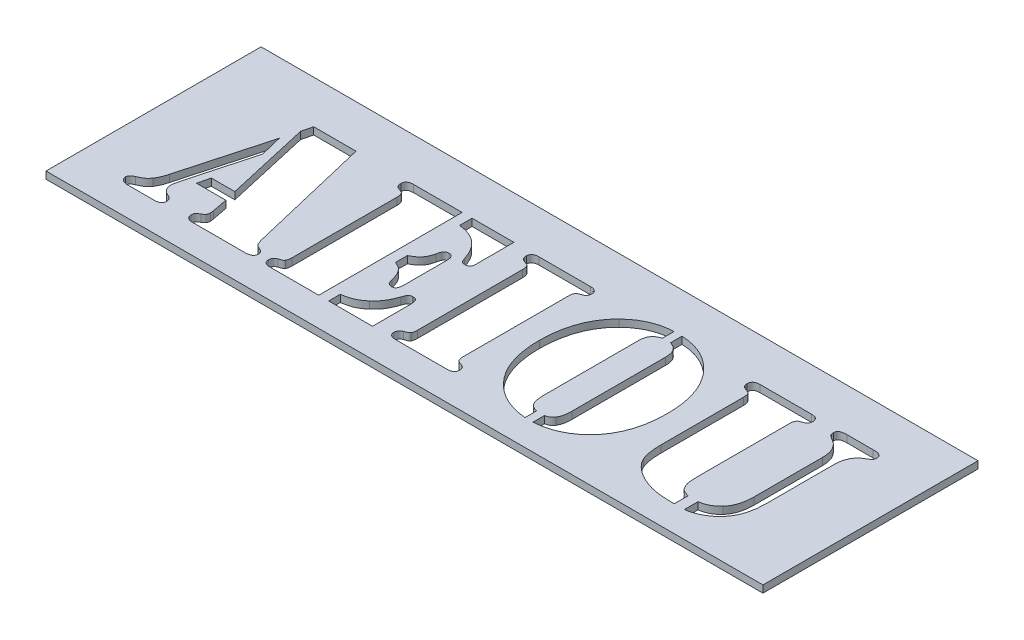
from build123d import *

# Parameters (mm, degrees)
SKETCH1_W           = 50
SKETCH1_H           = 15
BOSS_EXTRUDE1_DEPTH = 0.5
CUT_EXTRUDE1_REACH  = 2.5


with BuildPart() as part:
    # Sketch1 → Boss-Extrude1 (new body)
    with BuildSketch(Plane(origin=(0, 0, 0), x_dir=(1, 0, 0), z_dir=(0, 1, 0))):
        Rectangle(SKETCH1_W, SKETCH1_H)
    extrude(amount=BOSS_EXTRUDE1_DEPTH)

    # Sketch2 → Cut-Extrude1 (cut, up to next)
    with BuildSketch(Plane(origin=(0, 0.5, 0), x_dir=(1, 0, 0), z_dir=(0, 1, 0)), mode=Mode.PRIVATE) as cut_extrude1_sk1:
        with BuildLine():
            Line((-18.337673611, 4.507033689), (-15.386284722, 4.507033689))
            Line((-15.386284722, 4.507033689), (-13.335503472, -4.101907283))
            add(Edge.make_bspline(
                [(-13.335503472, -4.101907283), (-13.31571659, -4.173193323), (-13.277982556, -4.309137424), (-13.227253077, -4.440773778), (-13.203125, -4.503382978)],
                knots=[0, 0, 0, 0, 0.00022179, 0.000422958, 0.000422958, 0.000422958, 0.000422958], degree=3))
            add(Edge.make_bspline(
                [(-13.203125, -4.503382978), (-13.189801958, -4.526708407), (-13.162169427, -4.575086298), (-13.09409429, -4.634093988), (-13.009454398, -4.688410957), (-12.943250713, -4.716359995), (-12.907986111, -4.731247561)],
                knots=[0, 0, 0, 0, 8.006e-05, 0.000166048, 0.00026658, 0.000381166, 0.000381166, 0.000381166, 0.000381166], degree=3))
            add(Edge.make_bspline(
                [(-12.907986111, -4.731247561), (-12.852666047, -4.75584302), (-12.757778354, -4.79803036), (-12.641851728, -4.881220271), (-12.575758787, -4.989270356), (-12.571630909, -5.068863034), (-12.569444444, -5.111021867)],
                knots=[0, 0, 0, 0, 0.000181489, 0.000311299, 0.00042221, 0.00054712, 0.00054712, 0.00054712, 0.00054712], degree=3))
            add(Edge.make_bspline(
                [(-12.569444444, -5.111021867), (-12.570763223, -5.140939839), (-12.573307323, -5.198655589), (-12.602706683, -5.278735913), (-12.650267163, -5.347111766), (-12.717303399, -5.401839339), (-12.802967775, -5.442991364), (-12.905532483, -5.472848329), (-13.026827736, -5.489279696), (-13.113376601, -5.491680641), (-13.159722222, -5.492966311)],
                knots=[0, 0, 0, 0, 8.9398e-05, 0.000172461, 0.000251931, 0.000336677, 0.000428876, 0.000535302, 0.000655915, 0.000794957, 0.000794957, 0.000794957, 0.000794957], degree=3))
            Line((-13.159722222, -5.492966311), (-16.814236111, -5.492966311))
            add(Edge.make_bspline(
                [(-16.814236111, -5.492966311), (-16.848382867, -5.492037961), (-16.914538807, -5.490239376), (-17.00724797, -5.467551949), (-17.09105245, -5.435117567), (-17.162233739, -5.387795061), (-17.219559933, -5.328245792), (-17.262338966, -5.259855291), (-17.286573738, -5.181299037), (-17.289931903, -5.126374168), (-17.291666667, -5.098001033)],
                knots=[0, 0, 0, 0, 0.000102204, 0.00019801, 0.000284653, 0.000370723, 0.000452067, 0.000530972, 0.000610589, 0.000695669, 0.000695669, 0.000695669, 0.000695669], degree=3))
            add(Edge.make_bspline(
                [(-17.291666667, -5.098001033), (-17.290296603, -5.054174847), (-17.287858408, -4.976180792), (-17.249915704, -4.884635257), (-17.198259915, -4.82860937), (-17.141642569, -4.786075371), (-17.071172085, -4.735594692), (-17.01571023, -4.704618629), (-16.985677083, -4.687844783)],
                knots=[0, 0, 0, 0, 0.000130858, 0.000232877, 0.000288205, 0.000357684, 0.000444976, 0.000548075, 0.000548075, 0.000548075, 0.000548075], degree=3))
            add(Edge.make_bspline(
                [(-16.985677083, -4.687844783), (-16.9451778, -4.662997846), (-16.87225783, -4.618260316), (-16.78822521, -4.527889373), (-16.740696936, -4.419393316), (-16.737706092, -4.341127905), (-16.736111111, -4.299389922)],
                knots=[0, 0, 0, 0, 0.000142057, 0.000255777, 0.000364631, 0.000489012, 0.000489012, 0.000489012, 0.000489012], degree=3))
            add(Edge.make_bspline(
                [(-16.736111111, -4.299389922), (-16.736415512, -4.259500284), (-16.736988204, -4.184452867), (-16.749691292, -4.110507236), (-16.755642361, -4.075865617)],
                knots=[0, 0, 0, 0, 0.000119437, 0.000224705, 0.000224705, 0.000224705, 0.000224705], degree=3))
            Line((-16.755642361, -4.075865617), (-16.968315972, -2.992966311))
            Line((-16.968315972, -2.992966311), (-19.010416667, -2.992966311))
            Line((-19.010416667, -2.992966311), (-18.812934028, -2.159632978))
            Line((-18.812934028, -2.159632978), (-17.172309028, -2.159632978))
            Line((-17.172309028, -2.159632978), (-18.519965278, 3.777867022))
            Line((-18.519965278, 3.777867022), (-18.337673611, 4.507033689))
        make_face()
    cut_extrude1_tool1 = extrude(cut_extrude1_sk1.sketch, amount=-CUT_EXTRUDE1_REACH, mode=Mode.PRIVATE) & part.part
    add(cut_extrude1_tool1.solids().sort_by_distance((-15.934964, 0.5, 0.750702))[0], mode=Mode.SUBTRACT)
    # Sketch2 → Cut-Extrude1 (cut, up to next)
    with BuildSketch(Plane(origin=(0, 0.5, 0), x_dir=(1, 0, 0), z_dir=(0, 1, 0)), mode=Mode.PRIVATE) as cut_extrude1_sk2:
        with BuildLine():
            Line((-18.843315972, 2.619012856), (-18.470052083, 1.095575356))
            Line((-18.470052083, 1.095575356), (-19.735243056, -3.613626033))
            add(Edge.make_bspline(
                [(-19.735243056, -3.613626033), (-19.75113154, -3.678415772), (-19.781579767, -3.802576928), (-19.78840363, -3.930202275), (-19.791666667, -3.9912302)],
                knots=[0, 0, 0, 0, 0.000199617, 0.000382541, 0.000382541, 0.000382541, 0.000382541], degree=3))
            add(Edge.make_bspline(
                [(-19.791666667, -3.9912302), (-19.787963166, -4.062970612), (-19.780891211, -4.19996126), (-19.702393275, -4.386972131), (-19.578817938, -4.544382617), (-19.46462721, -4.611690815), (-19.405381944, -4.646612144)],
                knots=[0, 0, 0, 0, 0.000214009, 0.000408657, 0.000598455, 0.000803105, 0.000803105, 0.000803105, 0.000803105], degree=3))
            Line((-19.405381944, -4.646612144), (-19.175347222, -4.763799644))
            add(Edge.make_bspline(
                [(-19.175347222, -4.763799644), (-19.142106966, -4.783717378), (-19.078737399, -4.82168875), (-19.00680033, -4.907779295), (-18.964568383, -5.012653825), (-18.960459118, -5.088926146), (-18.958333333, -5.128382978)],
                knots=[0, 0, 0, 0, 0.000115569, 0.000220322, 0.000330337, 0.000448246, 0.000448246, 0.000448246, 0.000448246], degree=3))
            add(Edge.make_bspline(
                [(-18.958333333, -5.128382978), (-18.959020346, -5.156816813), (-18.960335004, -5.211227419), (-18.985850009, -5.286539465), (-19.023169141, -5.351042161), (-19.074519983, -5.406256547), (-19.144270206, -5.443927793), (-19.226280524, -5.472489442), (-19.322985388, -5.489340254), (-19.392295496, -5.491705239), (-19.429253472, -5.492966311)],
                knots=[0, 0, 0, 0, 8.4885e-05, 0.000162436, 0.000235386, 0.000307525, 0.000385317, 0.000470424, 0.000567476, 0.000678344, 0.000678344, 0.000678344, 0.000678344], degree=3))
            Line((-19.429253472, -5.492966311), (-21.2890625, -5.492966311))
            add(Edge.make_bspline(
                [(-21.2890625, -5.492966311), (-21.331854338, -5.492048359), (-21.413714078, -5.49029234), (-21.529085555, -5.468108104), (-21.63155355, -5.433861621), (-21.718141382, -5.38471791), (-21.788376453, -5.322204498), (-21.839322542, -5.248007396), (-21.868381196, -5.161482218), (-21.872739289, -5.101107781), (-21.875, -5.069789228)],
                knots=[0, 0, 0, 0, 0.000128204, 0.00024525, 0.000350943, 0.000451076, 0.000541729, 0.000630811, 0.000717968, 0.000811913, 0.000811913, 0.000811913, 0.000811913], degree=3))
            add(Edge.make_bspline(
                [(-21.875, -5.069789228), (-21.871241677, -5.034860509), (-21.863453385, -4.962478467), (-21.794191419, -4.865733653), (-21.689498084, -4.781855681), (-21.602045649, -4.740843279), (-21.553819444, -4.718226728)],
                knots=[0, 0, 0, 0, 0.00010385, 0.000215206, 0.000344688, 0.00050388, 0.00050388, 0.00050388, 0.00050388], degree=3))
            add(Edge.make_bspline(
                [(-21.553819444, -4.718226728), (-21.506631177, -4.697629331), (-21.4179337, -4.658913412), (-21.296373128, -4.599119387), (-21.196233501, -4.540066501), (-21.084561047, -4.466021097), (-20.960504741, -4.354339601), (-20.878678201, -4.248760553), (-20.835503472, -4.193053117)],
                knots=[0, 0, 0, 0, 0.000154461, 0.000290334, 0.000406086, 0.000502992, 0.000692043, 0.000903217, 0.000903217, 0.000903217, 0.000903217], degree=3))
            add(Edge.make_bspline(
                [(-20.835503472, -4.193053117), (-20.801818581, -4.139426182), (-20.731441334, -4.027384375), (-20.644343492, -3.838823248), (-20.562546251, -3.627682914), (-20.520894771, -3.475912121), (-20.499131944, -3.396612144)],
                knots=[0, 0, 0, 0, 0.00018981, 0.000396566, 0.000621864, 0.000868392, 0.000868392, 0.000868392, 0.000868392], degree=3))
            Line((-20.499131944, -3.396612144), (-18.843315972, 2.619012856))
        make_face()
    cut_extrude1_tool2 = extrude(cut_extrude1_sk2.sketch, amount=-CUT_EXTRUDE1_REACH, mode=Mode.PRIVATE) & part.part
    add(cut_extrude1_tool2.solids().sort_by_distance((-19.837536, 0.5, 2.589434))[0], mode=Mode.SUBTRACT)
    # Sketch2 → Cut-Extrude1 (cut, up to next)
    with BuildSketch(Plane(origin=(0, 0.5, 0), x_dir=(1, 0, 0), z_dir=(0, 1, 0)), mode=Mode.PRIVATE) as cut_extrude1_sk3:
        with BuildLine():
            Line((-7.986111111, 4.507033689), (-7.986111111, -5.492966311))
            Line((-7.986111111, -5.492966311), (-11.187065972, -5.492966311))
            Line((-11.187065972, -5.492966311), (-11.378038194, -5.492966311))
            add(Edge.make_bspline(
                [(-11.378038194, -5.492966311), (-11.415734546, -5.491718984), (-11.486509234, -5.489377135), (-11.586733015, -5.472032688), (-11.674261968, -5.442864847), (-11.747034819, -5.39861559), (-11.806665932, -5.343796693), (-11.844521933, -5.274744009), (-11.87067092, -5.197499905), (-11.873501501, -5.142374945), (-11.875, -5.113192006)],
                knots=[0, 0, 0, 0, 0.000113035, 0.000212222, 0.000304191, 0.000387932, 0.000466207, 0.000544, 0.00062155, 0.000708789, 0.000708789, 0.000708789, 0.000708789], degree=3))
            add(Edge.make_bspline(
                [(-11.875, -5.113192006), (-11.872047558, -5.067075163), (-11.866494123, -4.980331052), (-11.814398118, -4.861973807), (-11.723355218, -4.771569958), (-11.645072128, -4.7380814), (-11.603732639, -4.720396867)],
                knots=[0, 0, 0, 0, 0.000137817, 0.000259228, 0.000378921, 0.000512855, 0.000512855, 0.000512855, 0.000512855], degree=3))
            add(Edge.make_bspline(
                [(-11.603732639, -4.720396867), (-11.569685212, -4.708241351), (-11.510203504, -4.687005361), (-11.433201524, -4.657612075), (-11.379181117, -4.638852896), (-11.33541294, -4.62199473), (-11.295582717, -4.590150305), (-11.274903721, -4.557098147), (-11.263020833, -4.5381052)],
                knots=[0, 0, 0, 0, 0.000108464, 0.000189489, 0.000247151, 0.000280205, 0.000329692, 0.000396545, 0.000396545, 0.000396545, 0.000396545], degree=3))
            add(Edge.make_bspline(
                [(-11.263020833, -4.5381052), (-11.249721562, -4.516134601), (-11.221073296, -4.468807227), (-11.197388785, -4.382380337), (-11.181799641, -4.280462451), (-11.180992777, -4.206882707), (-11.180555556, -4.16701145)],
                knots=[0, 0, 0, 0, 7.6726e-05, 0.000165277, 0.000266253, 0.000385689, 0.000385689, 0.000385689, 0.000385689], degree=3))
            Line((-11.180555556, -4.16701145), (-11.180555556, 3.155037161))
            add(Edge.make_bspline(
                [(-11.180555556, 3.155037161), (-11.181085636, 3.195612043), (-11.182074586, 3.271310878), (-11.196757568, 3.37560309), (-11.221597027, 3.463786992), (-11.249769855, 3.512091591), (-11.263020833, 3.534811467)],
                knots=[0, 0, 0, 0, 0.000121605, 0.000226874, 0.000315425, 0.000394061, 0.000394061, 0.000394061, 0.000394061], degree=3))
            add(Edge.make_bspline(
                [(-11.263020833, 3.534811467), (-11.27491005, 3.553787726), (-11.295600059, 3.586810843), (-11.335370591, 3.618812666), (-11.379555471, 3.635299177), (-11.432563262, 3.657444964), (-11.510360933, 3.685467304), (-11.569742521, 3.70696688), (-11.603732639, 3.719273272)],
                knots=[0, 0, 0, 0, 6.6853e-05, 0.00011634, 0.000149394, 0.000207827, 0.000288852, 0.000397316, 0.000397316, 0.000397316, 0.000397316], degree=3))
            add(Edge.make_bspline(
                [(-11.603732639, 3.719273272), (-11.645307941, 3.736725906), (-11.725002164, 3.770180241), (-11.813794063, 3.865445165), (-11.866611021, 3.985651947), (-11.872088746, 4.073865817), (-11.875, 4.120748967)],
                knots=[0, 0, 0, 0, 0.000133935, 0.000256735, 0.000380128, 0.000520097, 0.000520097, 0.000520097, 0.000520097], degree=3))
            add(Edge.make_bspline(
                [(-11.875, 4.120748967), (-11.873466435, 4.150633704), (-11.87056708, 4.207133722), (-11.845038305, 4.286097394), (-11.806604348, 4.355639572), (-11.74710385, 4.410669351), (-11.673812929, 4.454249548), (-11.587250182, 4.486806964), (-11.486427418, 4.503220442), (-11.415706114, 4.505708492), (-11.378038194, 4.507033689)],
                knots=[0, 0, 0, 0, 8.9398e-05, 0.000169016, 0.000246809, 0.000325084, 0.000408825, 0.000501533, 0.00060072, 0.000713755, 0.000713755, 0.000713755, 0.000713755], degree=3))
            Line((-11.378038194, 4.507033689), (-11.187065972, 4.507033689))
            Line((-11.187065972, 4.507033689), (-7.986111111, 4.507033689))
        make_face()
    cut_extrude1_tool3 = extrude(cut_extrude1_sk3.sketch, amount=-CUT_EXTRUDE1_REACH, mode=Mode.PRIVATE) & part.part
    add(cut_extrude1_tool3.solids().sort_by_distance((-9.643945, 0.5, 0.4917))[0], mode=Mode.SUBTRACT)
    # Sketch2 → Cut-Extrude1 (cut, up to next)
    with BuildSketch(Plane(origin=(0, 0.5, 0), x_dir=(1, 0, 0), z_dir=(0, 1, 0)), mode=Mode.PRIVATE) as cut_extrude1_sk4:
        with BuildLine():
            Line((-7.291666667, 4.507033689), (-4.375, 4.507033689))
            Line((-4.375, 4.507033689), (-4.375, 1.874655217))
            add(Edge.make_bspline(
                [(-4.375, 1.874655217), (-4.375142515, 1.83979283), (-4.375406039, 1.775328797), (-4.394584754, 1.686721636), (-4.418381545, 1.610801577), (-4.458588591, 1.550396857), (-4.510969484, 1.50434005), (-4.576059238, 1.474974141), (-4.652224237, 1.4540813), (-4.707580347, 1.452389752), (-4.737413194, 1.451478133)],
                knots=[0, 0, 0, 0, 0.000104257, 0.000192782, 0.000271027, 0.000341448, 0.000407593, 0.000477477, 0.000553803, 0.000643016, 0.000643016, 0.000643016, 0.000643016], degree=3))
            add(Edge.make_bspline(
                [(-4.737413194, 1.451478133), (-4.783166633, 1.454292744), (-4.864361998, 1.459287633), (-4.961916961, 1.499883234), (-5.007499181, 1.563147057), (-5.043170528, 1.622892329), (-5.076658193, 1.700436418), (-5.095977961, 1.758752155), (-5.106336806, 1.7900198)],
                knots=[0, 0, 0, 0, 0.000137817, 0.000244573, 0.000300156, 0.000368265, 0.000453759, 0.000552589, 0.000552589, 0.000552589, 0.000552589], degree=3))
            add(Edge.make_bspline(
                [(-5.106336806, 1.7900198), (-5.154432703, 1.925909722), (-5.246724198, 2.186669677), (-5.432796711, 2.543225001), (-5.65238284, 2.848016138), (-5.906870473, 3.103657718), (-6.196968911, 3.310815802), (-6.527236633, 3.467510134), (-6.894786798, 3.582305839), (-7.156334657, 3.618223312), (-7.291666667, 3.636807994)],
                knots=[0, 0, 0, 0, 0.000432054, 0.000829071, 0.001201943, 0.001554883, 0.001906552, 0.002265676, 0.002647324, 0.003056538, 0.003056538, 0.003056538, 0.003056538], degree=3))
            Line((-7.291666667, 3.636807994), (-7.291666667, 4.507033689))
        make_face()
    cut_extrude1_tool4 = extrude(cut_extrude1_sk4.sketch, amount=-CUT_EXTRUDE1_REACH, mode=Mode.PRIVATE) & part.part
    add(cut_extrude1_tool4.solids().sort_by_distance((-5.46488, 0.5, -3.429356))[0], mode=Mode.SUBTRACT)
    # Sketch2 → Cut-Extrude1 (cut, up to next)
    with BuildSketch(Plane(origin=(0, 0.5, 0), x_dir=(1, 0, 0), z_dir=(0, 1, 0)), mode=Mode.PRIVATE) as cut_extrude1_sk5:
        with BuildLine():
            Line((-7.291666667, -0.851039228), (-7.291666667, -0.0068552))
            add(Edge.make_bspline(
                [(-7.291666667, -0.0068552), (-7.227635008, 0.027877684), (-7.105237776, 0.09426998), (-6.93635889, 0.200205559), (-6.798654485, 0.317803711), (-6.6809029, 0.438287035), (-6.588038715, 0.577000689), (-6.507511755, 0.730780446), (-6.442633332, 0.906126489), (-6.411537258, 1.030848356), (-6.395399306, 1.095575356)],
                knots=[0, 0, 0, 0, 0.000218582, 0.000417821, 0.000596486, 0.000760744, 0.000921466, 0.001095213, 0.001280629, 0.001480671, 0.001480671, 0.001480671, 0.001480671], degree=3))
            add(Edge.make_bspline(
                [(-6.395399306, 1.095575356), (-6.386107869, 1.139198457), (-6.369042952, 1.219317889), (-6.333625507, 1.327400225), (-6.296665359, 1.414657552), (-6.25135665, 1.482349561), (-6.197411524, 1.531479427), (-6.135554325, 1.567477738), (-6.063077838, 1.587136658), (-6.012124521, 1.589251365), (-5.985243056, 1.590367022)],
                knots=[0, 0, 0, 0, 0.000133706, 0.000245568, 0.000340758, 0.000417207, 0.000487862, 0.000557847, 0.000629985, 0.000710544, 0.000710544, 0.000710544, 0.000710544], degree=3))
            add(Edge.make_bspline(
                [(-5.985243056, 1.590367022), (-5.950095918, 1.588982531), (-5.883295321, 1.58635117), (-5.793223499, 1.547505383), (-5.720724744, 1.485314004), (-5.690630735, 1.430298507), (-5.674913194, 1.401564939)],
                knots=[0, 0, 0, 0, 0.00010473, 0.00019905, 0.000288264, 0.000385799, 0.000385799, 0.000385799, 0.000385799], degree=3))
            add(Edge.make_bspline(
                [(-5.674913194, 1.401564939), (-5.666934147, 1.380052299), (-5.647713417, 1.328230494), (-5.636692181, 1.23100867), (-5.624172412, 1.10460153), (-5.624704157, 1.009562515), (-5.625, 0.956686467)],
                knots=[0, 0, 0, 0, 6.8626e-05, 0.000165313, 0.000291648, 0.000450083, 0.000450083, 0.000450083, 0.000450083], degree=3))
            Line((-5.625, 0.956686467), (-5.625, -1.818921172))
            add(Edge.make_bspline(
                [(-5.625, -1.818921172), (-5.625764447, -1.872464188), (-5.627172135, -1.971060691), (-5.638656283, -2.106505705), (-5.66162695, -2.215257957), (-5.693106585, -2.30113506), (-5.741154251, -2.36363081), (-5.803875932, -2.407240963), (-5.882023898, -2.433398926), (-5.9394547, -2.436016299), (-5.970052083, -2.437410756)],
                knots=[0, 0, 0, 0, 0.000160649, 0.000295826, 0.000406928, 0.000493571, 0.000567801, 0.000639448, 0.000719743, 0.000811302, 0.000811302, 0.000811302, 0.000811302], degree=3))
            add(Edge.make_bspline(
                [(-5.970052083, -2.437410756), (-6.019746209, -2.43310677), (-6.114599549, -2.424891564), (-6.217602219, -2.353995936), (-6.27336733, -2.271946988), (-6.311582169, -2.193368166), (-6.347006429, -2.098291899), (-6.364338969, -2.028206003), (-6.373697917, -1.990362144)],
                knots=[0, 0, 0, 0, 0.000147713, 0.000281946, 0.000356619, 0.000443966, 0.000543532, 0.000660398, 0.000660398, 0.000660398, 0.000660398], degree=3))
            add(Edge.make_bspline(
                [(-6.373697917, -1.990362144), (-6.393675917, -1.910256924), (-6.431844618, -1.757212968), (-6.513243125, -1.547151143), (-6.602507344, -1.363566939), (-6.710724579, -1.211479897), (-6.832272929, -1.085052144), (-6.968287431, -0.981000856), (-7.122866093, -0.901446968), (-7.234588839, -0.868083982), (-7.291666667, -0.851039228)],
                knots=[0, 0, 0, 0, 0.000247434, 0.000472732, 0.000674601, 0.000858257, 0.001030151, 0.00119899, 0.001369811, 0.001548238, 0.001548238, 0.001548238, 0.001548238], degree=3))
        make_face()
    cut_extrude1_tool5 = extrude(cut_extrude1_sk5.sketch, amount=-CUT_EXTRUDE1_REACH, mode=Mode.PRIVATE) & part.part
    add(cut_extrude1_tool5.solids().sort_by_distance((-6.242191, 0.5, 0.41604))[0], mode=Mode.SUBTRACT)
    # Sketch2 → Cut-Extrude1 (cut, up to next)
    with BuildSketch(Plane(origin=(0, 0.5, 0), x_dir=(1, 0, 0), z_dir=(0, 1, 0)), mode=Mode.PRIVATE) as cut_extrude1_sk6:
        with BuildLine():
            Line((-7.291666667, -5.492966311), (-7.291666667, -4.685674644))
            add(Edge.make_bspline(
                [(-7.291666667, -4.685674644), (-7.215597208, -4.672576709), (-7.069315869, -4.647389418), (-6.860813059, -4.60086497), (-6.673588692, -4.543465203), (-6.501404602, -4.481341049), (-6.342464288, -4.399566429), (-6.184288901, -4.305913852), (-6.027201681, -4.193554934), (-5.926082643, -4.108398961), (-5.874565972, -4.065014922)],
                knots=[0, 0, 0, 0, 0.000231565, 0.000445299, 0.000640274, 0.000818833, 0.000993525, 0.00117552, 0.001370023, 0.001572032, 0.001572032, 0.001572032, 0.001572032], degree=3))
            add(Edge.make_bspline(
                [(-5.874565972, -4.065014922), (-5.776817748, -3.973793712), (-5.590195801, -3.799633209), (-5.398821034, -3.544867268), (-5.272841712, -3.327661352), (-5.184249868, -3.14260185), (-5.095131538, -2.936068105), (-5.042528294, -2.787866818), (-5.015190972, -2.710848256)],
                knots=[0, 0, 0, 0, 0.000400513, 0.000764663, 0.000950397, 0.001153244, 0.001379782, 0.001624892, 0.001624892, 0.001624892, 0.001624892], degree=3))
            add(Edge.make_bspline(
                [(-5.015190972, -2.710848256), (-5.001897739, -2.673790969), (-4.977345045, -2.605345907), (-4.936980055, -2.512962537), (-4.893755081, -2.440827729), (-4.836190652, -2.368517059), (-4.737773384, -2.308471768), (-4.649373675, -2.301952042), (-4.602864583, -2.298521867)],
                knots=[0, 0, 0, 0, 0.000118108, 0.000218147, 0.000301887, 0.000369684, 0.000494368, 0.000632799, 0.000632799, 0.000632799, 0.000632799], degree=3))
            add(Edge.make_bspline(
                [(-4.602864583, -2.298521867), (-4.570959118, -2.30041317), (-4.511375565, -2.303945186), (-4.42827902, -2.323761959), (-4.362288052, -2.364835693), (-4.311228512, -2.42268634), (-4.277661776, -2.500918236), (-4.251664888, -2.597937028), (-4.237728146, -2.717702161), (-4.236677979, -2.80486029), (-4.236111111, -2.851907283)],
                knots=[0, 0, 0, 0, 9.588e-05, 0.000179056, 0.000253127, 0.000325397, 0.000406943, 0.000505917, 0.000626237, 0.000767363, 0.000767363, 0.000767363, 0.000767363], degree=3))
            Line((-4.236111111, -2.851907283), (-4.236111111, -5.492966311))
            Line((-4.236111111, -5.492966311), (-7.291666667, -5.492966311))
        make_face()
    cut_extrude1_tool6 = extrude(cut_extrude1_sk6.sketch, amount=-CUT_EXTRUDE1_REACH, mode=Mode.PRIVATE) & part.part
    add(cut_extrude1_tool6.solids().sort_by_distance((-5.354481, 0.5, 4.370492))[0], mode=Mode.SUBTRACT)
    # Sketch2 → Cut-Extrude1 (cut, up to next)
    with BuildSketch(Plane(origin=(0, 0.5, 0), x_dir=(1, 0, 0), z_dir=(0, 1, 0)), mode=Mode.PRIVATE) as cut_extrude1_sk7:
        with BuildLine():
            Line((0.770399306, -5.492966311), (-2.437065972, -5.492966311))
            Line((-2.437065972, -5.492966311), (-2.628038194, -5.492966311))
            add(Edge.make_bspline(
                [(-2.628038194, -5.492966311), (-2.665734546, -5.491718984), (-2.736509234, -5.489377135), (-2.836733015, -5.472032688), (-2.924261968, -5.442864847), (-2.997034819, -5.39861559), (-3.056665932, -5.343796693), (-3.094521933, -5.274744009), (-3.12067092, -5.197499905), (-3.123501501, -5.142374945), (-3.125, -5.113192006)],
                knots=[0, 0, 0, 0, 0.000113035, 0.000212222, 0.000304191, 0.000387932, 0.000466207, 0.000544, 0.00062155, 0.000708789, 0.000708789, 0.000708789, 0.000708789], degree=3))
            add(Edge.make_bspline(
                [(-3.125, -5.113192006), (-3.122047558, -5.067075163), (-3.116494123, -4.980331052), (-3.064398118, -4.861973807), (-2.973355218, -4.771569958), (-2.895072128, -4.7380814), (-2.853732639, -4.720396867)],
                knots=[0, 0, 0, 0, 0.000137817, 0.000259228, 0.000378921, 0.000512855, 0.000512855, 0.000512855, 0.000512855], degree=3))
            add(Edge.make_bspline(
                [(-2.853732639, -4.720396867), (-2.819685212, -4.708241351), (-2.760203504, -4.687005361), (-2.683201524, -4.657612075), (-2.629181117, -4.638852896), (-2.58541294, -4.62199473), (-2.545582717, -4.590150305), (-2.524903721, -4.557098147), (-2.513020833, -4.5381052)],
                knots=[0, 0, 0, 0, 0.000108464, 0.000189489, 0.000247151, 0.000280205, 0.000329692, 0.000396545, 0.000396545, 0.000396545, 0.000396545], degree=3))
            add(Edge.make_bspline(
                [(-2.513020833, -4.5381052), (-2.499721562, -4.516134601), (-2.471073296, -4.468807227), (-2.447388785, -4.382380337), (-2.431799641, -4.280462451), (-2.430992777, -4.206882707), (-2.430555556, -4.16701145)],
                knots=[0, 0, 0, 0, 7.6726e-05, 0.000165277, 0.000266253, 0.000385689, 0.000385689, 0.000385689, 0.000385689], degree=3))
            Line((-2.430555556, -4.16701145), (-2.430555556, 3.155037161))
            add(Edge.make_bspline(
                [(-2.430555556, 3.155037161), (-2.431085636, 3.195612043), (-2.432074586, 3.271310878), (-2.446757568, 3.37560309), (-2.471597027, 3.463786992), (-2.499769855, 3.512091591), (-2.513020833, 3.534811467)],
                knots=[0, 0, 0, 0, 0.000121605, 0.000226874, 0.000315425, 0.000394061, 0.000394061, 0.000394061, 0.000394061], degree=3))
            add(Edge.make_bspline(
                [(-2.513020833, 3.534811467), (-2.52491005, 3.553787726), (-2.545600059, 3.586810843), (-2.585370591, 3.618812666), (-2.629555471, 3.635299177), (-2.682563262, 3.657444964), (-2.760360933, 3.685467304), (-2.819742521, 3.70696688), (-2.853732639, 3.719273272)],
                knots=[0, 0, 0, 0, 6.6853e-05, 0.00011634, 0.000149394, 0.000207827, 0.000288852, 0.000397316, 0.000397316, 0.000397316, 0.000397316], degree=3))
            add(Edge.make_bspline(
                [(-2.853732639, 3.719273272), (-2.895307941, 3.736725906), (-2.975002164, 3.770180241), (-3.063794063, 3.865445165), (-3.116611021, 3.985651947), (-3.122088746, 4.073865817), (-3.125, 4.120748967)],
                knots=[0, 0, 0, 0, 0.000133935, 0.000256735, 0.000380128, 0.000520097, 0.000520097, 0.000520097, 0.000520097], degree=3))
            add(Edge.make_bspline(
                [(-3.125, 4.120748967), (-3.123466435, 4.150633704), (-3.12056708, 4.207133722), (-3.095038305, 4.286097394), (-3.056604348, 4.355639572), (-2.99710385, 4.410669351), (-2.923812929, 4.454249548), (-2.837250182, 4.486806964), (-2.736427418, 4.503220442), (-2.665706114, 4.505708492), (-2.628038194, 4.507033689)],
                knots=[0, 0, 0, 0, 8.9398e-05, 0.000169016, 0.000246809, 0.000325084, 0.000408825, 0.000501533, 0.00060072, 0.000713755, 0.000713755, 0.000713755, 0.000713755], degree=3))
            Line((-2.628038194, 4.507033689), (-2.437065972, 4.507033689))
            Line((-2.437065972, 4.507033689), (0.770399306, 4.507033689))
            Line((0.770399306, 4.507033689), (0.961371528, 4.507033689))
            add(Edge.make_bspline(
                [(0.961371528, 4.507033689), (0.99902501, 4.505672993), (1.06971921, 4.503118293), (1.170050395, 4.487254698), (1.255432353, 4.453668014), (1.328459968, 4.410823357), (1.387429437, 4.355004749), (1.428825272, 4.286797017), (1.453737105, 4.207034976), (1.456743272, 4.150599543), (1.458333333, 4.120748967)],
                knots=[0, 0, 0, 0, 0.000113035, 0.000212222, 0.000302902, 0.000386642, 0.000464918, 0.000543823, 0.00062344, 0.000712839, 0.000712839, 0.000712839, 0.000712839], degree=3))
            add(Edge.make_bspline(
                [(1.458333333, 4.120748967), (1.455422079, 4.073865817), (1.449944354, 3.985651947), (1.397127397, 3.865445165), (1.308335498, 3.770180241), (1.228641275, 3.736725906), (1.187065972, 3.719273272)],
                knots=[0, 0, 0, 0, 0.00013997, 0.000263363, 0.000386163, 0.000520097, 0.000520097, 0.000520097, 0.000520097], degree=3))
            add(Edge.make_bspline(
                [(1.187065972, 3.719273272), (1.153059126, 3.707016915), (1.093648312, 3.685604751), (1.015380162, 3.656865066), (0.961389584, 3.635553293), (0.916872884, 3.619239442), (0.879006507, 3.585857494), (0.858381309, 3.553613728), (0.846354167, 3.534811467)],
                knots=[0, 0, 0, 0, 0.000108464, 0.000189489, 0.000249942, 0.000282996, 0.000330789, 0.000397641, 0.000397641, 0.000397641, 0.000397641], degree=3))
            add(Edge.make_bspline(
                [(0.846354167, 3.534811467), (0.832873596, 3.512154179), (0.804317845, 3.464159485), (0.783681901, 3.374940476), (0.76427582, 3.271638055), (0.764023783, 3.195687136), (0.763888889, 3.155037161)],
                knots=[0, 0, 0, 0, 7.8636e-05, 0.000166573, 0.000272177, 0.000393782, 0.000393782, 0.000393782, 0.000393782], degree=3))
            Line((0.763888889, 3.155037161), (0.763888889, -4.16701145))
            add(Edge.make_bspline(
                [(0.763888889, -4.16701145), (0.763925248, -4.206960488), (0.763992452, -4.28080057), (0.784300197, -4.381715539), (0.80380566, -4.4691761), (0.832830063, -4.516195986), (0.846354167, -4.5381052)],
                knots=[0, 0, 0, 0, 0.000119437, 0.000220761, 0.000308699, 0.000385425, 0.000385425, 0.000385425, 0.000385425], degree=3))
            add(Edge.make_bspline(
                [(0.846354167, -4.5381052), (0.858375481, -4.556923467), (0.878990683, -4.58919468), (0.916910432, -4.622430069), (0.961030017, -4.639104185), (1.015986245, -4.65705328), (1.093501913, -4.687129197), (1.153005832, -4.708286431), (1.187065972, -4.720396867)],
                knots=[0, 0, 0, 0, 6.6853e-05, 0.000114645, 0.0001477, 0.000207408, 0.000288433, 0.000396897, 0.000396897, 0.000396897, 0.000396897], degree=3))
            add(Edge.make_bspline(
                [(1.187065972, -4.720396867), (1.228405461, -4.7380814), (1.306688551, -4.771569958), (1.397731452, -4.861973807), (1.449827456, -4.980331052), (1.455380892, -5.067075163), (1.458333333, -5.113192006)],
                knots=[0, 0, 0, 0, 0.000133935, 0.000253627, 0.000375039, 0.000512855, 0.000512855, 0.000512855, 0.000512855], degree=3))
            add(Edge.make_bspline(
                [(1.458333333, -5.113192006), (1.45678028, -5.142342004), (1.453846647, -5.197404741), (1.428288993, -5.275432372), (1.387490285, -5.343162373), (1.328388782, -5.39876629), (1.255895927, -5.442290542), (1.169516431, -5.472470036), (1.069805026, -5.489280045), (0.999054833, -5.491685243), (0.961371528, -5.492966311)],
                knots=[0, 0, 0, 0, 8.7239e-05, 0.000164789, 0.000243693, 0.000321969, 0.000405709, 0.000495633, 0.00059482, 0.000707855, 0.000707855, 0.000707855, 0.000707855], degree=3))
            Line((0.961371528, -5.492966311), (0.770399306, -5.492966311))
        make_face()
    cut_extrude1_tool7 = extrude(cut_extrude1_sk7.sketch, amount=-CUT_EXTRUDE1_REACH, mode=Mode.PRIVATE) & part.part
    add(cut_extrude1_tool7.solids().sort_by_distance((-0.833364, 0.5, 0.490512))[0], mode=Mode.SUBTRACT)
    # Sketch2 → Cut-Extrude1 (cut, up to next)
    with BuildSketch(Plane(origin=(0, 0.5, 0), x_dir=(1, 0, 0), z_dir=(0, 1, 0)), mode=Mode.PRIVATE) as cut_extrude1_sk8:
        with BuildLine():
            add(Edge.make_bspline(
                [(6.597222222, 3.905905217), (6.537967892, 3.882791211), (6.425837781, 3.839051353), (6.275413432, 3.753624415), (6.152548713, 3.656030221), (6.053519568, 3.544410772), (5.985481519, 3.408710809), (5.935601491, 3.251481711), (5.909252157, 3.066186614), (5.905029636, 2.934478257), (5.902777778, 2.86423855)],
                knots=[0, 0, 0, 0, 0.000190639, 0.000360756, 0.000516659, 0.000659773, 0.000804409, 0.000968438, 0.0011529, 0.001363683, 0.001363683, 0.001363683, 0.001363683], degree=3))
            Line((5.902777778, 2.86423855), (5.902777778, -3.670049644))
            add(Edge.make_bspline(
                [(5.902777778, -3.670049644), (5.904128244, -3.769350753), (5.906622472, -3.952753709), (5.942204985, -4.20399337), (5.991756127, -4.41230182), (6.054639288, -4.524551828), (6.082899306, -4.574997561)],
                knots=[0, 0, 0, 0, 0.000297507, 0.000549477, 0.000761129, 0.000933884, 0.000933884, 0.000933884, 0.000933884], degree=3))
            add(Edge.make_bspline(
                [(6.082899306, -4.574997561), (6.109679505, -4.609669956), (6.165945458, -4.682517631), (6.284716053, -4.768326802), (6.430915076, -4.837678285), (6.539515281, -4.870210763), (6.597222222, -4.887497561)],
                knots=[0, 0, 0, 0, 0.000130876, 0.000274974, 0.00043415, 0.000614637, 0.000614637, 0.000614637, 0.000614637], degree=3))
            Line((6.597222222, -4.887497561), (6.597222222, -5.688278811))
            add(Edge.make_bspline(
                [(6.597222222, -5.688278811), (6.463794356, -5.674648809), (6.200313105, -5.647733518), (5.815584739, -5.568261499), (5.447107845, -5.460355318), (5.096342049, -5.319868406), (4.760540671, -5.153338218), (4.442700684, -4.954430224), (4.140660498, -4.726093511), (3.9560796, -4.552169852), (3.862847222, -4.464320478)],
                knots=[0, 0, 0, 0, 0.00040215, 0.000794129, 0.001176597, 0.001552582, 0.001926231, 0.002299577, 0.002675888, 0.003059959, 0.003059959, 0.003059959, 0.003059959], degree=3))
            add(Edge.make_bspline(
                [(3.862847222, -4.464320478), (3.747746555, -4.342428363), (3.518281865, -4.099424243), (3.226312282, -3.688257115), (2.980683394, -3.24276188), (2.777842708, -2.762907031), (2.622119463, -2.246855526), (2.510318279, -1.697006699), (2.441597866, -1.111752557), (2.434303745, -0.710173952), (2.430555556, -0.503817006)],
                knots=[0, 0, 0, 0, 0.000502466, 0.001001716, 0.001507805, 0.002026141, 0.002561598, 0.00312212, 0.003707596, 0.004326466, 0.004326466, 0.004326466, 0.004326466], degree=3))
            add(Edge.make_bspline(
                [(2.430555556, -0.503817006), (2.434881391, -0.295983082), (2.443348957, 0.110839524), (2.517098555, 0.70462232), (2.632848285, 1.267976644), (2.797497847, 1.79903176), (3.009535067, 2.295873918), (3.270672192, 2.75347614), (3.569891943, 3.178727082), (3.810177465, 3.424932957), (3.930121528, 3.5478323)],
                knots=[0, 0, 0, 0, 0.000623287, 0.001220048, 0.001792076, 0.002346681, 0.002885243, 0.003409056, 0.003925212, 0.004439663, 0.004439663, 0.004439663, 0.004439663], degree=3))
            add(Edge.make_bspline(
                [(3.930121528, 3.5478323), (4.024866737, 3.635619454), (4.211349561, 3.808407043), (4.512125249, 4.034501006), (4.823979769, 4.226705588), (5.148047336, 4.386488137), (5.485592463, 4.515607742), (5.840555395, 4.610751473), (6.212394476, 4.677014013), (6.467477853, 4.695243944), (6.597222222, 4.704516328)],
                knots=[0, 0, 0, 0, 0.000387295, 0.000762296, 0.001126679, 0.001484805, 0.001844721, 0.00220902, 0.002585781, 0.002975785, 0.002975785, 0.002975785, 0.002975785], degree=3))
            Line((6.597222222, 4.704516328), (6.597222222, 3.905905217))
        make_face()
    cut_extrude1_tool8 = extrude(cut_extrude1_sk8.sketch, amount=-CUT_EXTRUDE1_REACH, mode=Mode.PRIVATE) & part.part
    add(cut_extrude1_tool8.solids().sort_by_distance((4.51651, 0.5, 0.485854))[0], mode=Mode.SUBTRACT)
    # Sketch2 → Cut-Extrude1 (cut, up to next)
    with BuildSketch(Plane(origin=(0, 0.5, 0), x_dir=(1, 0, 0), z_dir=(0, 1, 0)), mode=Mode.PRIVATE) as cut_extrude1_sk9:
        with BuildLine():
            Line((7.152777778, 3.905905217), (7.152777778, 4.704516328))
            add(Edge.make_bspline(
                [(7.152777778, 4.704516328), (7.282537425, 4.69531796), (7.536939728, 4.677283956), (7.90856088, 4.610085805), (8.263850278, 4.516151728), (8.602383704, 4.385869926), (8.927788332, 4.227362973), (9.240003049, 4.034413563), (9.540831568, 3.808430012), (9.727307104, 3.635627192), (9.822048611, 3.5478323)],
                knots=[0, 0, 0, 0, 0.000390004, 0.000764628, 0.001131021, 0.001490937, 0.001851011, 0.002215394, 0.002590395, 0.00297769, 0.00297769, 0.00297769, 0.00297769], degree=3))
            add(Edge.make_bspline(
                [(9.822048611, 3.5478323), (9.942464742, 3.423301438), (10.182905994, 3.174644083), (10.486144654, 2.751005977), (10.742988312, 2.293926889), (10.95776375, 1.804100017), (11.119301498, 1.276427878), (11.236076087, 0.714985049), (11.306089203, 0.117162199), (11.314913102, -0.293123013), (11.319444444, -0.503817006)],
                knots=[0, 0, 0, 0, 0.000519112, 0.001036539, 0.001557395, 0.002089982, 0.002637726, 0.003209754, 0.003808414, 0.004440375, 0.004440375, 0.004440375, 0.004440375], degree=3))
            add(Edge.make_bspline(
                [(11.319444444, -0.503817006), (11.315702667, -0.710176801), (11.308421023, -1.111760952), (11.239612149, -1.696975776), (11.128124814, -2.246964104), (10.971382664, -2.762257772), (10.772465514, -3.243931196), (10.52319996, -3.687636127), (10.231886116, -4.098854896), (10.003644941, -4.342355347), (9.889322917, -4.464320478)],
                knots=[0, 0, 0, 0, 0.00061887, 0.001204345, 0.001764867, 0.002300325, 0.00281782, 0.003324964, 0.003824214, 0.00432523, 0.00432523, 0.00432523, 0.00432523], degree=3))
            add(Edge.make_bspline(
                [(9.889322917, -4.464320478), (9.796228688, -4.553061735), (9.612267316, -4.7284213), (9.308722484, -4.956159048), (8.99235887, -5.158140702), (8.655671443, -5.32385139), (8.305494517, -5.465423912), (7.936142573, -5.569562167), (7.55136334, -5.650834443), (7.286976457, -5.67567177), (7.152777778, -5.688278811)],
                knots=[0, 0, 0, 0, 0.000385534, 0.000761845, 0.001136344, 0.001509992, 0.001885978, 0.002267836, 0.002659815, 0.003063869, 0.003063869, 0.003063869, 0.003063869], degree=3))
            Line((7.152777778, -5.688278811), (7.152777778, -4.887497561))
            add(Edge.make_bspline(
                [(7.152777778, -4.887497561), (7.210569476, -4.872908309), (7.314536875, -4.84666221), (7.45255882, -4.781491593), (7.561954782, -4.68986517), (7.61799472, -4.614677422), (7.647569444, -4.574997561)],
                knots=[0, 0, 0, 0, 0.000178559, 0.000321228, 0.000453767, 0.000601878, 0.000601878, 0.000601878, 0.000601878], degree=3))
            add(Edge.make_bspline(
                [(7.647569444, -4.574997561), (7.678649376, -4.519515093), (7.744946677, -4.401164189), (7.804590715, -4.189787872), (7.84057749, -3.94260829), (7.844908104, -3.76497188), (7.847222222, -3.670049644)],
                knots=[0, 0, 0, 0, 0.000190231, 0.000405786, 0.000653771, 0.000938357, 0.000938357, 0.000938357, 0.000938357], degree=3))
            Line((7.847222222, -3.670049644), (7.847222222, 2.86423855))
            add(Edge.make_bspline(
                [(7.847222222, 2.86423855), (7.845537328, 2.926540279), (7.842330196, 3.045129265), (7.819040073, 3.212704356), (7.779626904, 3.36144939), (7.735818987, 3.447863474), (7.71484375, 3.48923855)],
                knots=[0, 0, 0, 0, 0.000186834, 0.000355631, 0.000506764, 0.000645602, 0.000645602, 0.000645602, 0.000645602], degree=3))
            add(Edge.make_bspline(
                [(7.71484375, 3.48923855), (7.68421467, 3.53701377), (7.625613774, 3.62841941), (7.503879709, 3.743199997), (7.343601618, 3.83268741), (7.221537991, 3.879522392), (7.152777778, 3.905905217)],
                knots=[0, 0, 0, 0, 0.000169785, 0.00032484, 0.000496047, 0.000716901, 0.000716901, 0.000716901, 0.000716901], degree=3))
        make_face()
    cut_extrude1_tool9 = extrude(cut_extrude1_sk9.sketch, amount=-CUT_EXTRUDE1_REACH, mode=Mode.PRIVATE) & part.part
    add(cut_extrude1_tool9.solids().sort_by_distance((9.233634, 0.5, 0.487523))[0], mode=Mode.SUBTRACT)
    # Sketch2 → Cut-Extrude1 (cut, up to next)
    with BuildSketch(Plane(origin=(0, 0.5, 0), x_dir=(1, 0, 0), z_dir=(0, 1, 0)), mode=Mode.PRIVATE) as cut_extrude1_sk10:
        with BuildLine():
            Line((12.986111111, -2.5849802), (12.986111111, 3.155037161))
            add(Edge.make_bspline(
                [(12.986111111, 3.155037161), (12.98558103, 3.195612043), (12.984592081, 3.271310878), (12.969909098, 3.37560309), (12.94506964, 3.463786992), (12.916896811, 3.512091591), (12.903645833, 3.534811467)],
                knots=[0, 0, 0, 0, 0.000121605, 0.000226874, 0.000315425, 0.000394061, 0.000394061, 0.000394061, 0.000394061], degree=3))
            add(Edge.make_bspline(
                [(12.903645833, 3.534811467), (12.891756617, 3.553787726), (12.871066607, 3.586810843), (12.831296076, 3.618812666), (12.787111195, 3.635299177), (12.734103404, 3.657444964), (12.656305734, 3.685467304), (12.596924146, 3.70696688), (12.562934028, 3.719273272)],
                knots=[0, 0, 0, 0, 6.6853e-05, 0.00011634, 0.000149394, 0.000207827, 0.000288852, 0.000397316, 0.000397316, 0.000397316, 0.000397316], degree=3))
            add(Edge.make_bspline(
                [(12.562934028, 3.719273272), (12.521464683, 3.73683416), (12.44245756, 3.770291048), (12.352912605, 3.862956474), (12.300047364, 3.981256266), (12.294575657, 4.068079593), (12.291666667, 4.11423855)],
                knots=[0, 0, 0, 0, 0.000133935, 0.000255171, 0.000376583, 0.0005144, 0.0005144, 0.0005144, 0.0005144], degree=3))
            add(Edge.make_bspline(
                [(12.291666667, 4.11423855), (12.293296953, 4.144787622), (12.296381824, 4.202593372), (12.320620677, 4.284113448), (12.363267525, 4.353570298), (12.423144325, 4.410948271), (12.499080931, 4.453552388), (12.58715469, 4.487604848), (12.690466823, 4.502897682), (12.763285507, 4.505606549), (12.801649306, 4.507033689)],
                knots=[0, 0, 0, 0, 9.1558e-05, 0.000173249, 0.000252154, 0.000333498, 0.000419101, 0.00051181, 0.000615273, 0.000730475, 0.000730475, 0.000730475, 0.000730475], degree=3))
            Line((12.801649306, 4.507033689), (12.979600694, 4.507033689))
            Line((12.979600694, 4.507033689), (16.187065972, 4.507033689))
            Line((16.187065972, 4.507033689), (16.378038194, 4.507033689))
            Line((16.378038194, 4.507033689), (16.642795139, 4.476651744))
            add(Edge.make_bspline(
                [(16.642795139, 4.476651744), (16.675443587, 4.461377994), (16.741898, 4.430288979), (16.814276066, 4.342970215), (16.869301492, 4.236484447), (16.873042474, 4.154807243), (16.875, 4.112068411)],
                knots=[0, 0, 0, 0, 0.000106867, 0.000217523, 0.00033303, 0.000459812, 0.000459812, 0.000459812, 0.000459812], degree=3))
            add(Edge.make_bspline(
                [(16.875, 4.112068411), (16.872001275, 4.066649182), (16.866318864, 3.980582376), (16.8137544, 3.862957631), (16.724209011, 3.770290723), (16.645201951, 3.736834048), (16.603732639, 3.719273272)],
                knots=[0, 0, 0, 0, 0.000135664, 0.000257076, 0.000378312, 0.000512247, 0.000512247, 0.000512247, 0.000512247], degree=3))
            add(Edge.make_bspline(
                [(16.603732639, 3.719273272), (16.569596529, 3.707352089), (16.509714118, 3.686439652), (16.432475525, 3.654305476), (16.37803453, 3.633439427), (16.333546032, 3.61705251), (16.295670442, 3.583694432), (16.27504697, 3.551446196), (16.263020833, 3.532641328)],
                knots=[0, 0, 0, 0, 0.000108464, 0.000190269, 0.000250722, 0.000283777, 0.000331569, 0.000398422, 0.000398422, 0.000398422, 0.000398422], degree=3))
            add(Edge.make_bspline(
                [(16.263020833, 3.532641328), (16.249508664, 3.510729821), (16.220509876, 3.463705013), (16.200462011, 3.374881481), (16.180906596, 3.27165672), (16.180677937, 3.195693644), (16.180555556, 3.155037161)],
                knots=[0, 0, 0, 0, 7.6726e-05, 0.000164663, 0.000270267, 0.000391872, 0.000391872, 0.000391872, 0.000391872], degree=3))
            Line((16.180555556, 3.155037161), (16.180555556, -2.971264922))
            add(Edge.make_bspline(
                [(16.180555556, -2.971264922), (16.180748594, -3.06748829), (16.181101344, -3.243322236), (16.188866884, -3.484141628), (16.194678512, -3.677705038), (16.214687682, -3.869658839), (16.253093378, -4.071461907), (16.318038541, -4.212833521), (16.349826389, -4.282028811)],
                knots=[0, 0, 0, 0, 0.000288637, 0.000527441, 0.000722946, 0.000869137, 0.001106645, 0.001334345, 0.001334345, 0.001334345, 0.001334345], degree=3))
            add(Edge.make_bspline(
                [(16.349826389, -4.282028811), (16.380774157, -4.335601735), (16.437591873, -4.433957495), (16.537453442, -4.537470602), (16.639107422, -4.593495848), (16.73899452, -4.634645965), (16.863454126, -4.683883787), (16.956507768, -4.71310353), (17.007378472, -4.729077422)],
                knots=[0, 0, 0, 0, 0.000185417, 0.000340411, 0.000423047, 0.000531901, 0.000664493, 0.000824392, 0.000824392, 0.000824392, 0.000824392], degree=3))
            Line((17.007378472, -4.729077422), (17.007378472, -5.688278811))
            Line((17.007378472, -5.688278811), (16.846788194, -5.688278811))
            add(Edge.make_bspline(
                [(16.846788194, -5.688278811), (16.696981825, -5.686253044), (16.410782484, -5.682382894), (16.00070407, -5.651796113), (15.629295329, -5.603496074), (15.398215934, -5.547658579), (15.288628472, -5.521178117)],
                knots=[0, 0, 0, 0, 0.00044935, 0.000858466, 0.001233196, 0.001571209, 0.001571209, 0.001571209, 0.001571209], degree=3))
            add(Edge.make_bspline(
                [(15.288628472, -5.521178117), (15.16997918, -5.48643723), (14.937289102, -5.418304842), (14.606565488, -5.28116299), (14.295686231, -5.125903328), (14.011914905, -4.944876657), (13.758217888, -4.746994943), (13.541960475, -4.535473207), (13.360473164, -4.314294326), (13.27373329, -4.151228311), (13.231336806, -4.071525339)],
                knots=[0, 0, 0, 0, 0.000370643, 0.00072689, 0.001072399, 0.00141194, 0.001734941, 0.002035723, 0.002318383, 0.002588633, 0.002588633, 0.002588633, 0.002588633], degree=3))
            add(Edge.make_bspline(
                [(13.231336806, -4.071525339), (13.211789482, -4.026961897), (13.171095298, -3.934188432), (13.122779271, -3.784181889), (13.078200755, -3.620147764), (13.044523453, -3.440835013), (13.01930131, -3.247300577), (12.999006805, -3.039633765), (12.989120147, -2.817280969), (12.98713254, -2.663835615), (12.986111111, -2.5849802)],
                knots=[0, 0, 0, 0, 0.0001459, 0.00030374, 0.000472188, 0.000655626, 0.000850516, 0.001057602, 0.00128139, 0.001517975, 0.001517975, 0.001517975, 0.001517975], degree=3))
        make_face()
    cut_extrude1_tool10 = extrude(cut_extrude1_sk10.sketch, amount=-CUT_EXTRUDE1_REACH, mode=Mode.PRIVATE) & part.part
    add(cut_extrude1_tool10.solids().sort_by_distance((14.692551, 0.5, 0.304522))[0], mode=Mode.SUBTRACT)
    # Sketch2 → Cut-Extrude1 (cut, up to next)
    with BuildSketch(Plane(origin=(0, 0.5, 0), x_dir=(1, 0, 0), z_dir=(0, 1, 0)), mode=Mode.PRIVATE) as cut_extrude1_sk11:
        with BuildLine():
            Line((17.708333333, -5.688278811), (17.708333333, -4.735587839))
            add(Edge.make_bspline(
                [(17.708333333, -4.735587839), (17.819444738, -4.715050608), (18.037067886, -4.674826324), (18.341320559, -4.545378775), (18.621342374, -4.3728887), (18.775946426, -4.217444798), (18.854166667, -4.138799644)],
                knots=[0, 0, 0, 0, 0.000338013, 0.000662033, 0.000985929, 0.001317613, 0.001317613, 0.001317613, 0.001317613], degree=3))
            add(Edge.make_bspline(
                [(18.854166667, -4.138799644), (18.89580357, -4.089021646), (18.979832185, -3.988563256), (19.086728253, -3.819738711), (19.17482004, -3.634027224), (19.249401024, -3.433870435), (19.304703043, -3.21761836), (19.346360709, -2.987084989), (19.369791543, -2.740265428), (19.373227081, -2.570560413), (19.375, -2.482983672)],
                knots=[0, 0, 0, 0, 0.000194539, 0.000392605, 0.000597405, 0.000810256, 0.001032385, 0.001266086, 0.001512471, 0.001775201, 0.001775201, 0.001775201, 0.001775201], degree=3))
            Line((19.375, -2.482983672), (19.375, 2.276130911))
            add(Edge.make_bspline(
                [(19.375, 2.276130911), (19.373511571, 2.358046436), (19.370636436, 2.516279142), (19.331866036, 2.743214196), (19.274598321, 2.951577726), (19.191832427, 3.140666904), (19.083426667, 3.309094163), (18.955448658, 3.461836006), (18.798518808, 3.590431329), (18.681520086, 3.659991892), (18.621961806, 3.695401744)],
                knots=[0, 0, 0, 0, 0.000245466, 0.000474155, 0.000688483, 0.000892523, 0.001090589, 0.001287606, 0.001487941, 0.001695664, 0.001695664, 0.001695664, 0.001695664], degree=3))
            add(Edge.make_bspline(
                [(18.621961806, 3.695401744), (18.58774255, 3.714549882), (18.525681035, 3.749277769), (18.442765948, 3.802594084), (18.379083804, 3.850475732), (18.315070954, 3.910388999), (18.271237198, 4.014221767), (18.266511221, 4.102273251), (18.263888889, 4.151130911)],
                knots=[0, 0, 0, 0, 0.000117629, 0.000213337, 0.000295372, 0.000356753, 0.000474222, 0.000620654, 0.000620654, 0.000620654, 0.000620654], degree=3))
            add(Edge.make_bspline(
                [(18.263888889, 4.151130911), (18.265413942, 4.180951844), (18.26830876, 4.237557184), (18.293912236, 4.316958482), (18.342285307, 4.379425219), (18.406794032, 4.430046706), (18.492081931, 4.46587082), (18.597546003, 4.490918312), (18.725001966, 4.505600702), (18.817233408, 4.506530237), (18.8671875, 4.507033689)],
                knots=[0, 0, 0, 0, 8.9398e-05, 0.000169693, 0.000245648, 0.000322925, 0.000413266, 0.000520639, 0.00064742, 0.000797222, 0.000797222, 0.000797222, 0.000797222], degree=3))
            Line((18.8671875, 4.507033689), (20.68359375, 4.507033689))
            add(Edge.make_bspline(
                [(20.68359375, 4.507033689), (20.71759045, 4.507167948), (20.77980645, 4.50741365), (20.86379969, 4.505924755), (20.92957306, 4.500838961), (20.993286766, 4.496571861), (21.061215272, 4.479815365), (21.107293946, 4.453230259), (21.130642361, 4.439759383)],
                knots=[0, 0, 0, 0, 0.000101997, 0.00018666, 0.000251908, 0.000299848, 0.000378274, 0.000458833, 0.000458833, 0.000458833, 0.000458833], degree=3))
            add(Edge.make_bspline(
                [(21.130642361, 4.439759383), (21.159252657, 4.420824535), (21.213240853, 4.3850941), (21.274876152, 4.311976221), (21.314498939, 4.227874185), (21.317787228, 4.166746686), (21.319444444, 4.135939939)],
                knots=[0, 0, 0, 0, 0.000102434, 0.000193295, 0.000283637, 0.000375426, 0.000375426, 0.000375426, 0.000375426], degree=3))
            add(Edge.make_bspline(
                [(21.319444444, 4.135939939), (21.318359477, 4.109748716), (21.316210107, 4.057862689), (21.294092676, 3.983585802), (21.256270388, 3.915894812), (21.220538566, 3.879138226), (21.202256944, 3.8603323)],
                knots=[0, 0, 0, 0, 7.8396e-05, 0.000155306, 0.000230136, 0.000308532, 0.000308532, 0.000308532, 0.000308532], degree=3))
            add(Edge.make_bspline(
                [(21.202256944, 3.8603323), (21.191509786, 3.851513508), (21.161053548, 3.826522041), (21.097880359, 3.784993596), (21.006070551, 3.725158901), (20.933399188, 3.682725362), (20.891927083, 3.658509383)],
                knots=[0, 0, 0, 0, 4.1687e-05, 0.000118136, 0.000226491, 0.000370524, 0.000370524, 0.000370524, 0.000370524], degree=3))
            add(Edge.make_bspline(
                [(20.891927083, 3.658509383), (20.839943167, 3.627046084), (20.73526884, 3.563691877), (20.601530334, 3.434329785), (20.481739948, 3.284967647), (20.384164766, 3.112162223), (20.305285275, 2.921952369), (20.250110651, 2.717663886), (20.213495739, 2.500963471), (20.210080926, 2.35224187), (20.208333333, 2.276130911)],
                knots=[0, 0, 0, 0, 0.000181774, 0.000366019, 0.000554459, 0.000754724, 0.000959052, 0.001170704, 0.001388336, 0.001616458, 0.001616458, 0.001616458, 0.001616458], degree=3))
            Line((20.208333333, 2.276130911), (20.208333333, -2.489494089))
            add(Edge.make_bspline(
                [(20.208333333, -2.489494089), (20.206567842, -2.589368228), (20.203121222, -2.784344138), (20.179050233, -3.070697631), (20.138695233, -3.343498312), (20.079740946, -3.602222271), (20.005824425, -3.847644232), (19.91531897, -4.079585413), (19.806655278, -4.298054463), (19.721190929, -4.433875522), (19.678819444, -4.501212839)],
                knots=[0, 0, 0, 0, 0.000299605, 0.000584894, 0.000861422, 0.001126233, 0.001380241, 0.001629694, 0.001872323, 0.00211089, 0.00211089, 0.00211089, 0.00211089], degree=3))
            add(Edge.make_bspline(
                [(19.678819444, -4.501212839), (19.609854288, -4.595349152), (19.470619771, -4.785401994), (19.208705274, -5.033122937), (18.908416962, -5.255206985), (18.683095428, -5.372259739), (18.567708333, -5.432202422)],
                knots=[0, 0, 0, 0, 0.000349453, 0.000705515, 0.001076634, 0.00146616, 0.00146616, 0.00146616, 0.00146616], degree=3))
            add(Edge.make_bspline(
                [(18.567708333, -5.432202422), (18.505236165, -5.460838359), (18.377422308, -5.519425562), (18.169895478, -5.588041118), (17.946017447, -5.646845727), (17.788873505, -5.674239052), (17.708333333, -5.688278811)],
                knots=[0, 0, 0, 0, 0.000206026, 0.000421516, 0.000654692, 0.00089985, 0.00089985, 0.00089985, 0.00089985], degree=3))
        make_face()
    cut_extrude1_tool11 = extrude(cut_extrude1_sk11.sketch, amount=-CUT_EXTRUDE1_REACH, mode=Mode.PRIVATE) & part.part
    add(cut_extrude1_tool11.solids().sort_by_distance((19.587909, 0.5, -0.060572))[0], mode=Mode.SUBTRACT)


solid = part.part
